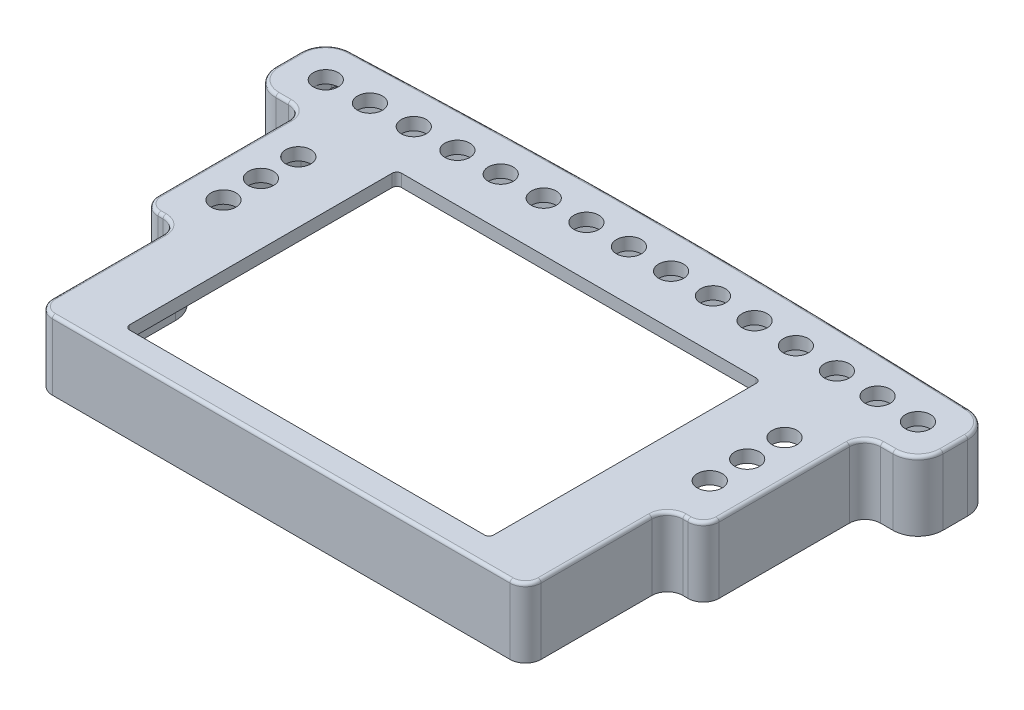
from build123d import *

# Parameters (mm, degrees)
SKETCH1_R           = 2
SKETCH1_W           = 58.4
SKETCH1_H           = 43.6
BOSS_EXTRUDE1_DEPTH = 2
BOSS_EXTRUDE2_DEPTH = 9.1
BOSS_EXTRUDE3_DEPTH = 1.7
FILLET1_R           = 0.5
FILLET2_R           = 0.75


with BuildPart() as part:
    # Sketch1 → Boss-Extrude1 (new body)
    with BuildSketch(Plane(origin=(0, 0, 0), x_dir=(1, 0, 0), z_dir=(0, 1, 0))):
        with BuildLine():
            ThreePointArc((347.444756382, 24.053208833), (348.176989429, 22.28544188), (349.944756382, 21.553208833))
            Line((349.944756382, 21.553208833), (423.344756382, 21.553208833))
            ThreePointArc((423.344756382, 21.553208833), (425.112523335, 22.28544188), (425.844756382, 24.053208833))
            Line((425.844756382, 24.053208833), (425.844756382, 41.803208833))
            ThreePointArc((425.844756382, 41.803208833), (426.576989429, 43.570975786), (428.344756382, 44.303208833))
            Line((428.344756382, 44.303208833), (429.144756382, 44.303208833))
            ThreePointArc((429.144756382, 44.303208833), (430.912523335, 45.03544188), (431.644756382, 46.803208833))
            Line((431.644756382, 46.803208833), (431.644756382, 67.705062276))
            ThreePointArc((431.644756382, 67.705062276), (432.376989429, 69.472829229), (434.144756382, 70.205062276))
            Line((434.144756382, 70.205062276), (436.144756382, 70.205062276))
            ThreePointArc((436.144756382, 70.205062276), (438.973183507, 71.376635152), (440.144756382, 74.205062276))
            Line((440.144756382, 74.205062276), (440.144756382, 78.182163129))
            ThreePointArc((440.144756382, 78.182163129), (439.026089436, 80.956675668), (436.295796466, 82.179310473))
            add(Edge.make_bspline(
                [(336.993716298, 82.179310473), (386.644756382, 84.055472801), (436.295796466, 82.179310473)],
                knots=[0.093713755, 0.093713755, 0.093713755, 0.906286245, 0.906286245, 0.906286245], degree=2, weights=[1.145596835, 1.711546023, 1.145596835]))
            ThreePointArc((336.993716298, 82.179310473), (334.263423328, 80.956675668), (333.144756382, 78.182163129))
            Line((333.144756382, 78.182163129), (333.144756382, 74.205062276))
            ThreePointArc((333.144756382, 74.205062276), (334.316329258, 71.376635152), (337.144756382, 70.205062276))
            Line((337.144756382, 70.205062276), (339.144756382, 70.205062276))
            ThreePointArc((339.144756382, 70.205062276), (340.912523335, 69.472829229), (341.644756382, 67.705062276))
            Line((341.644756382, 67.705062276), (341.644756382, 46.803208833))
            ThreePointArc((341.644756382, 46.803208833), (342.376989429, 45.03544188), (344.144756382, 44.303208833))
            Line((344.144756382, 44.303208833), (344.944756382, 44.303208833))
            ThreePointArc((344.944756382, 44.303208833), (346.712523335, 43.570975786), (347.444756382, 41.803208833))
            Line((347.444756382, 41.803208833), (347.444756382, 24.053208833))
        make_face()
        with Locations((347.644756382, 51.303208833)):
            Circle(SKETCH1_R, mode=Mode.SUBTRACT)
        with Locations((386.644756382, 47.503208833)):
            Rectangle(SKETCH1_W, SKETCH1_H, mode=Mode.SUBTRACT)
        with Locations((425.644756382, 51.303208833)):
            Circle(SKETCH1_R, mode=Mode.SUBTRACT)
        with Locations((347.644756382, 57.303208833)):
            Circle(SKETCH1_R, mode=Mode.SUBTRACT)
        with Locations((347.644756382, 63.303208833)):
            Circle(SKETCH1_R, mode=Mode.SUBTRACT)
        with BuildLine():
            ThreePointArc((341.142592859, 76.298064486), (341.144215428, 76.251575962), (341.144756382, 76.205062276))
            ThreePointArc((341.144756382, 76.205062276), (337.145297336, 76.15854859), (341.142592859, 76.298064486))
        make_face(mode=Mode.SUBTRACT)
        with BuildLine():
            ThreePointArc((347.926382755, 76.505305146), (345.968517745, 74.505749035), (343.928158112, 76.421053869))
            ThreePointArc((343.928158112, 76.421053869), (345.844946074, 78.503646475), (347.924836805, 76.583927069))
            ThreePointArc((347.924836805, 76.583927069), (347.92599623, 76.544623707), (347.926382755, 76.505305146))
        make_face(mode=Mode.SUBTRACT)
        with BuildLine():
            ThreePointArc((354.709895696, 76.759380351), (352.745589325, 74.759698885), (350.711169731, 76.688004462))
            ThreePointArc((350.711169731, 76.688004462), (352.642026077, 78.758228448), (354.708859774, 76.823743491))
            ThreePointArc((354.708859774, 76.823743491), (354.709636699, 76.791566089), (354.709895696, 76.759380351))
        make_face(mode=Mode.SUBTRACT)
        with BuildLine():
            ThreePointArc((361.494980912, 76.967276118), (359.524169989, 74.96748913), (357.495832914, 76.90890418))
            ThreePointArc((357.495832914, 76.90890418), (359.440681473, 78.966538875), (361.494350131, 77.017502831))
            ThreePointArc((361.494350131, 77.017502831), (361.49482321, 76.992391455), (361.494980912, 76.967276118))
        make_face(mode=Mode.SUBTRACT)
        with BuildLine():
            ThreePointArc((368.281324034, 77.128982816), (366.303945415, 75.129110752), (364.281835761, 77.083742948))
            ThreePointArc((364.281835761, 77.083742948), (366.240597272, 79.128568105), (368.280996154, 77.165196266))
            ThreePointArc((368.280996154, 77.165196266), (368.281242062, 77.147090283), (368.281324034, 77.128982816))
        make_face(mode=Mode.SUBTRACT)
        with BuildLine():
            ThreePointArc((375.068610638, 77.244492952), (373.084601228, 75.244556877), (371.068866337, 77.212512795))
            ThreePointArc((371.068866337, 77.212512795), (373.041458423, 79.244308632), (375.068486043, 77.266817066))
            ThreePointArc((375.068486043, 77.266817066), (375.068579489, 77.255655183), (375.068610638, 77.244492952))
        make_face(mode=Mode.SUBTRACT)
        with BuildLine():
            ThreePointArc((381.856526254, 77.313801174), (379.865823017, 75.313822782), (377.856612683, 77.295207848))
            ThreePointArc((377.856612683, 77.295207848), (379.842949834, 79.313755094), (381.856507938, 77.322360601))
            ThreePointArc((381.856507938, 77.322360601), (381.856521675, 77.318080897), (381.856526254, 77.313801174))
        make_face(mode=Mode.SUBTRACT)
        with BuildLine():
            ThreePointArc((388.644749931, 77.331824339), (386.644756382, 75.336904272), (384.644762834, 77.331824339))
            ThreePointArc((384.644762834, 77.331824339), (386.642216414, 79.336902659), (388.644756382, 77.336904272))
            ThreePointArc((388.644756382, 77.336904272), (388.64475477, 77.334364303), (388.644749931, 77.331824339))
        make_face(mode=Mode.SUBTRACT)
        with Locations((425.644756382, 57.303208833)):
            Circle(SKETCH1_R, mode=Mode.SUBTRACT)
        with Locations((425.644756382, 63.303208833)):
            Circle(SKETCH1_R, mode=Mode.SUBTRACT)
        with BuildLine():
            ThreePointArc((395.432900081, 77.295207848), (393.419410092, 75.313847254), (391.433004827, 77.322360601))
            ThreePointArc((391.433004827, 77.322360601), (393.437266234, 79.313796595), (395.432986511, 77.313801174))
            ThreePointArc((395.432986511, 77.313801174), (395.432964904, 77.30450441), (395.432900081, 77.295207848))
        make_face(mode=Mode.SUBTRACT)
        with BuildLine():
            ThreePointArc((402.220646428, 77.212512795), (400.193749912, 75.244677271), (398.221026722, 77.266817066))
            ThreePointArc((398.221026722, 77.266817066), (400.232064358, 79.244461803), (402.220902127, 77.244492952))
            ThreePointArc((402.220902127, 77.244492952), (402.220838201, 77.228502362), (402.220646428, 77.212512795))
        make_face(mode=Mode.SUBTRACT)
        with BuildLine():
            ThreePointArc((409.007677004, 77.083742948), (406.967461968, 75.129397526), (405.008516611, 77.165196266))
            ThreePointArc((405.008516611, 77.165196266), (407.026296198, 79.128900844), (409.008188731, 77.128982816))
            ThreePointArc((409.008188731, 77.128982816), (409.008060795, 77.106361435), (409.007677004, 77.083742948))
        make_face(mode=Mode.SUBTRACT)
        with BuildLine():
            ThreePointArc((436.144756382, 76.205062276), (434.098242696, 74.20560323), (432.146919905, 76.298064486))
            ThreePointArc((432.146919905, 76.298064486), (434.191270068, 78.204521322), (436.144756382, 76.205062276))
        make_face(mode=Mode.SUBTRACT)
        with BuildLine():
            ThreePointArc((415.793679851, 76.90890418), (413.740232415, 74.968013361), (411.795162633, 77.017502831))
            ThreePointArc((411.795162633, 77.017502831), (413.81964719, 78.967118417), (415.794531853, 76.967276118))
            ThreePointArc((415.794531853, 76.967276118), (415.794318841, 76.93808704), (415.793679851, 76.90890418))
        make_face(mode=Mode.SUBTRACT)
        with BuildLine():
            ThreePointArc((422.578343034, 76.688004462), (420.51174745, 74.760532254), (418.580652991, 76.823743491))
            ThreePointArc((418.580652991, 76.823743491), (420.611802807, 78.759121354), (422.579617069, 76.759380351))
            ThreePointArc((422.579617069, 76.759380351), (422.579298535, 76.723686721), (422.578343034, 76.688004462))
        make_face(mode=Mode.SUBTRACT)
        with BuildLine():
            ThreePointArc((429.361354653, 76.421053869), (427.281693329, 74.506963817), (425.364675959, 76.583927069))
            ThreePointArc((425.364675959, 76.583927069), (427.40244857, 78.504918622), (429.36313001, 76.505305146))
            ThreePointArc((429.36313001, 76.505305146), (429.362686122, 76.463170156), (429.361354653, 76.421053869))
        make_face(mode=Mode.SUBTRACT)
    extrude(amount=BOSS_EXTRUDE1_DEPTH)

    # Sketch2 → Boss-Extrude2 (add)
    with BuildSketch(Plane.XZ):
        with BuildLine():
            ThreePointArc((436.295796466, -82.179310473), (439.026089436, -80.956675668), (440.144756382, -78.182163129))
            Line((440.144756382, -78.182163129), (440.144756382, -74.205062276))
            ThreePointArc((440.144756382, -74.205062276), (438.973183507, -71.376635152), (436.144756382, -70.205062276))
            Line((436.144756382, -70.205062276), (434.144756382, -70.205062276))
            ThreePointArc((434.144756382, -70.205062276), (432.376989429, -69.472829229), (431.644756382, -67.705062276))
            Line((431.644756382, -67.705062276), (431.644756382, -46.803208833))
            ThreePointArc((431.644756382, -46.803208833), (430.912523335, -45.03544188), (429.144756382, -44.303208833))
            Line((429.144756382, -44.303208833), (428.344756382, -44.303208833))
            ThreePointArc((428.344756382, -44.303208833), (426.576989429, -43.570975786), (425.844756382, -41.803208833))
            Line((425.844756382, -41.803208833), (425.844756382, -24.053208833))
            ThreePointArc((425.844756382, -24.053208833), (425.112523335, -22.28544188), (423.344756382, -21.553208833))
            Line((423.344756382, -21.553208833), (349.944756382, -21.553208833))
            ThreePointArc((349.944756382, -21.553208833), (348.176989429, -22.28544188), (347.444756382, -24.053208833))
            Line((347.444756382, -24.053208833), (347.444756382, -41.803208833))
            ThreePointArc((347.444756382, -41.803208833), (346.712523335, -43.570975786), (344.944756382, -44.303208833))
            Line((344.944756382, -44.303208833), (344.144756382, -44.303208833))
            ThreePointArc((344.144756382, -44.303208833), (342.376989429, -45.03544188), (341.644756382, -46.803208833))
            Line((341.644756382, -46.803208833), (341.644756382, -67.705062276))
            ThreePointArc((341.644756382, -67.705062276), (340.912523335, -69.472829229), (339.144756382, -70.205062276))
            Line((339.144756382, -70.205062276), (337.144756382, -70.205062276))
            ThreePointArc((337.144756382, -70.205062276), (334.316329258, -71.376635152), (333.144756382, -74.205062276))
            Line((333.144756382, -74.205062276), (333.144756382, -78.182163129))
            ThreePointArc((333.144756382, -78.182163129), (334.263423328, -80.956675668), (336.993716298, -82.179310473))
            add(Edge.make_bspline(
                [(336.993716298, -82.179310473), (386.644756382, -84.055472801), (436.295796466, -82.179310473)],
                knots=[0.093713755, 0.093713755, 0.093713755, 0.906286245, 0.906286245, 0.906286245], degree=2, weights=[1.145596835, 1.711546023, 1.145596835]))
        make_face()
        with BuildLine():
            ThreePointArc((427.324756382, -46.186084601), (428.994224407, -47.242525969), (429.644756382, -49.10800178))
            Line((429.644756382, -49.10800178), (429.644756382, -67.705062276))
            ThreePointArc((429.644756382, -67.705062276), (430.962775867, -70.887042792), (434.144756382, -72.205062276))
            Line((434.144756382, -72.205062276), (436.144756382, -72.205062276))
            ThreePointArc((436.144756382, -72.205062276), (437.558969945, -72.790848714), (438.144756382, -74.205062276))
            Line((438.144756382, -74.205062276), (438.144756382, -78.182163129))
            ThreePointArc((438.144756382, -78.182163129), (437.585422909, -79.569419399), (436.220276424, -80.180736801))
            add(Edge.make_bspline(
                [(337.06923634, -80.180736801), (340.533443213, -80.311526525), (346.709704887, -80.529358601), (353.201892925, -80.740297317), (359.800861735, -80.927830927), (367.293438888, -81.107063657), (376.685008657, -81.261368099), (386.644756382, -81.317155744), (396.604504108, -81.261368099), (405.996073876, -81.107063657), (413.48865103, -80.927830927), (420.08761984, -80.740297317), (426.579807877, -80.529358601), (432.756069551, -80.311526525), (436.220276424, -80.180736801)],
                knots=[0.093713755, 0.093713755, 0.093713755, 0.13180309, 0.169892426, 0.220678206, 0.271463987, 0.347642658, 0.449214219, 0.550785781, 0.652357342, 0.728536013, 0.779321794, 0.830107574, 0.86819691, 0.906286245, 0.906286245, 0.906286245], degree=2))
            ThreePointArc((337.06923634, -80.180736801), (335.704089855, -79.569419399), (335.144756382, -78.182163129))
            Line((335.144756382, -78.182163129), (335.144756382, -74.205062276))
            ThreePointArc((335.144756382, -74.205062276), (335.73054282, -72.790848714), (337.144756382, -72.205062276))
            Line((337.144756382, -72.205062276), (339.144756382, -72.205062276))
            ThreePointArc((339.144756382, -72.205062276), (342.326736898, -70.887042792), (343.644756382, -67.705062276))
            Line((343.644756382, -67.705062276), (343.644756382, -49.10800178))
            ThreePointArc((343.644756382, -49.10800178), (344.295288357, -47.242525969), (345.964756382, -46.186084601))
            ThreePointArc((345.964756382, -46.186084601), (348.46895842, -44.601422548), (349.444756382, -41.803208833))
            Line((349.444756382, -41.803208833), (349.444756382, -26.553208833))
            ThreePointArc((349.444756382, -26.553208833), (350.323436039, -24.431888489), (352.444756382, -23.553208833))
            Line((352.444756382, -23.553208833), (420.844756382, -23.553208833))
            ThreePointArc((420.844756382, -23.553208833), (422.966076726, -24.431888489), (423.844756382, -26.553208833))
            Line((423.844756382, -26.553208833), (423.844756382, -41.803208833))
            ThreePointArc((423.844756382, -41.803208833), (424.820554345, -44.601422548), (427.324756382, -46.186084601))
        make_face(mode=Mode.SUBTRACT)
    extrude(amount=BOSS_EXTRUDE2_DEPTH)

    # Sketch3 → Boss-Extrude3 (add)
    with BuildSketch(Plane.XZ):
        with BuildLine():
            ThreePointArc((345.964756382, -46.186084601), (344.393216419, -47.125435818), (343.660279668, -48.803208833))
            Line((343.660279668, -48.803208833), (344.644756382, -48.803208833))
            Line((344.644756382, -48.803208833), (350.644756382, -48.803208833))
            Line((350.644756382, -48.803208833), (350.644756382, -41.803208833))
            Line((350.644756382, -41.803208833), (349.444756382, -41.803208833))
            ThreePointArc((349.444756382, -41.803208833), (348.46895842, -44.601422548), (345.964756382, -46.186084601))
        make_face()
        with BuildLine():
            Line((344.644756382, -48.803208833), (343.660279668, -48.803208833))
            ThreePointArc((343.660279668, -48.803208833), (343.648639717, -48.955407782), (343.644756382, -49.10800178))
            Line((343.644756382, -49.10800178), (343.644756382, -49.803208833))
            ThreePointArc((343.644756382, -49.803208833), (343.937649601, -49.096102051), (344.644756382, -48.803208833))
        make_face()
        with BuildLine():
            Line((349.444756382, -40.603208833), (349.444756382, -41.803208833))
            Line((349.444756382, -41.803208833), (350.644756382, -41.803208833))
            ThreePointArc((350.644756382, -41.803208833), (349.796228245, -41.45173697), (349.444756382, -40.603208833))
        make_face()
        with BuildLine():
            Line((337.144756382, -72.205062276), (337.06923634, -80.180736801))
            ThreePointArc((337.06923634, -80.180736801), (335.704089855, -79.569419399), (335.144756382, -78.182163129))
            Line((335.144756382, -78.182163129), (335.144756382, -74.205062276))
            ThreePointArc((335.144756382, -74.205062276), (335.73054282, -72.790848714), (337.144756382, -72.205062276))
        make_face()
        with BuildLine():
            Line((338.135332414, -72.205062276), (337.144756382, -72.205062276))
            Line((337.144756382, -72.205062276), (337.13537724, -73.195593904))
            ThreePointArc((337.13537724, -73.195593904), (337.431581169, -72.494615807), (338.135332414, -72.205062276))
        make_face()
        with BuildLine():
            ThreePointArc((338.040987034, -80.217271528), (337.35490917, -79.908308259), (337.078442223, -79.208503168))
            Line((337.078442223, -79.208503168), (337.06923634, -80.180736801))
            add(Edge.make_bspline(
                [(337.06923634, -80.180736801), (337.558868134, -80.199222651), (338.040987034, -80.217271528)],
                knots=[0.093713755, 0.093713755, 0.093713755, 0.09909731, 0.09909731, 0.09909731], degree=2))
        make_face()
        with BuildLine():
            Line((436.144756382, -72.205062276), (436.220276424, -80.180736801))
            ThreePointArc((436.220276424, -80.180736801), (437.585422909, -79.569419399), (438.144756382, -78.182163129))
            Line((438.144756382, -78.182163129), (438.144756382, -74.205062276))
            ThreePointArc((438.144756382, -74.205062276), (437.558969945, -72.790848714), (436.144756382, -72.205062276))
        make_face()
        with BuildLine():
            ThreePointArc((435.154180351, -72.205062276), (435.857931595, -72.494615807), (436.154135525, -73.195593904))
            Line((436.154135525, -73.195593904), (436.144756382, -72.205062276))
            Line((436.144756382, -72.205062276), (435.154180351, -72.205062276))
        make_face()
        with BuildLine():
            ThreePointArc((436.211070542, -79.208503168), (435.934603595, -79.908308259), (435.248525731, -80.217271528))
            add(Edge.make_bspline(
                [(435.248525731, -80.217271528), (435.730644631, -80.199222651), (436.220276424, -80.180736801)],
                knots=[0.90090269, 0.90090269, 0.90090269, 0.906286245, 0.906286245, 0.906286245], degree=2))
            Line((436.220276424, -80.180736801), (436.211070542, -79.208503168))
        make_face()
        with BuildLine():
            Line((422.644756382, -48.803208833), (428.644756382, -48.803208833))
            Line((428.644756382, -48.803208833), (429.629233097, -48.803208833))
            ThreePointArc((429.629233097, -48.803208833), (428.896296346, -47.125435818), (427.324756382, -46.186084601))
            ThreePointArc((427.324756382, -46.186084601), (424.820554345, -44.601422548), (423.844756382, -41.803208833))
            Line((423.844756382, -41.803208833), (422.644756382, -41.803208833))
            Line((422.644756382, -41.803208833), (422.644756382, -48.803208833))
        make_face()
        with BuildLine():
            ThreePointArc((428.644756382, -48.803208833), (429.351863164, -49.096102051), (429.644756382, -49.803208833))
            Line((429.644756382, -49.803208833), (429.644756382, -49.10800178))
            ThreePointArc((429.644756382, -49.10800178), (429.640873048, -48.955407782), (429.629233097, -48.803208833))
            Line((429.629233097, -48.803208833), (428.644756382, -48.803208833))
        make_face()
        with BuildLine():
            ThreePointArc((423.844756382, -40.603208833), (423.49328452, -41.45173697), (422.644756382, -41.803208833))
            Line((422.644756382, -41.803208833), (423.844756382, -41.803208833))
            Line((423.844756382, -41.803208833), (423.844756382, -40.603208833))
        make_face()
    extrude(amount=BOSS_EXTRUDE3_DEPTH)

    # Fillet1
    fillet1_edges = [part.edges().sort_by_distance(p)[0] for p in [
        (334.263423328, 2, -80.956675668),
        (333.144756382, 2, -76.193612703),
        (334.316329258, 2, -71.376635152),
        (338.144756382, 2, -70.205062276),
        (340.912523335, 2, -69.472829229),
        (341.644756382, 2, -57.254135554),
        (342.376989429, 2, -45.03544188),
        (344.544756382, 2, -44.303208833),
        (346.712523335, 2, -43.570975786),
        (347.444756382, 2, -32.928208833),
        (348.176989429, 2, -22.28544188),
        (386.644756382, 2, -21.553208833),
        (425.112523335, 2, -22.28544188),
        (425.844756382, 2, -32.928208833),
        (426.576989429, 2, -43.570975786),
        (428.744756382, 2, -44.303208833),
        (430.912523335, 2, -45.03544188),
        (431.644756382, 2, -57.254135554),
        (432.376989429, 2, -69.472829229),
        (435.144756382, 2, -70.205062276),
        (438.973183507, 2, -71.376635152),
        (440.144756382, 2, -76.193612703),
        (439.026089436, 2, -80.956675668),
        (386.644366504, 2, -83.303208832),
    ]]
    fillet(fillet1_edges, radius=FILLET1_R)

    # Fillet2
    fillet2_edges = [part.edges().sort_by_distance(p)[0] for p in [
        (357.444756382, 1, -69.303208833),
        (357.444756382, 1, -25.703208833),
        (415.844756382, 1, -25.703208833),
        (415.844756382, 1, -69.303208833),
    ]]
    fillet(fillet2_edges, radius=FILLET2_R)


solid = part.part
